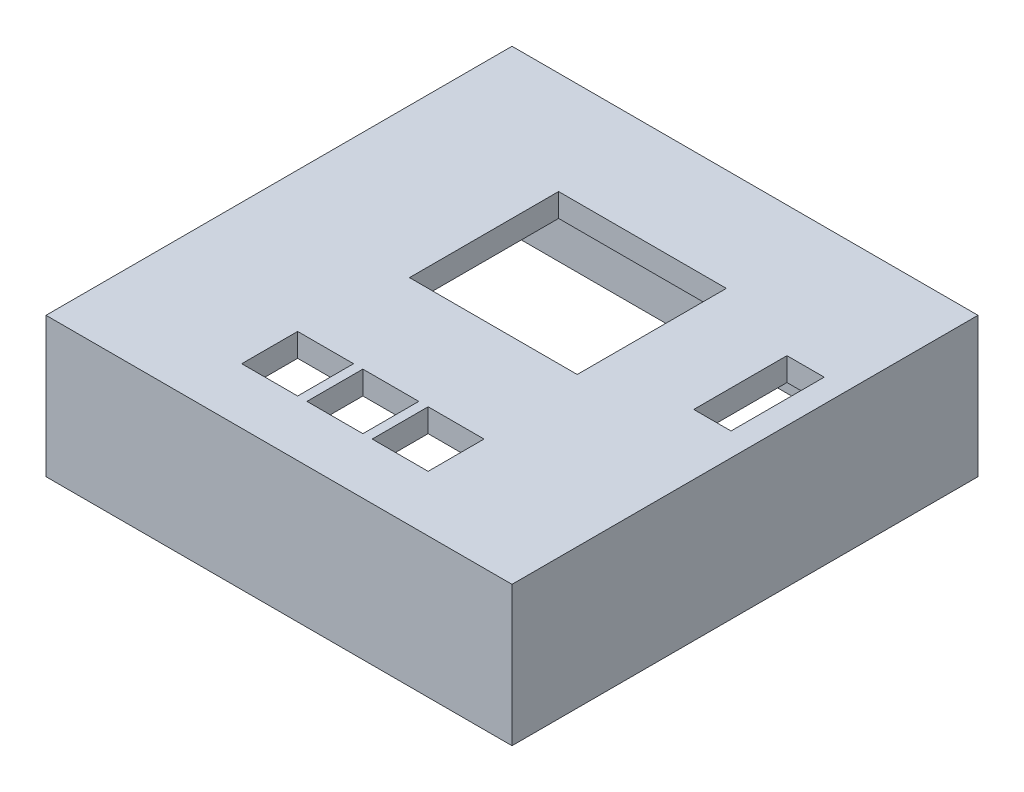
from build123d import *

# Parameters (mm, degrees)
SKETCH1_W                 = 100
SKETCH1_H                 = 100
BOSS_EXTRUDE1_DEPTH       = 30
SHELL2_T                  = -5
SKETCH2_W                 = 100
SKETCH2_H                 = 100
BOSS_EXTRUDE2_DEPTH       = 5
SKETCH3_W                 = 12
SKETCH3_H                 = 12
SKETCH3_W_2               = 36
SKETCH3_H_2               = 32
SKETCH3_W_3               = 8
SKETCH3_H_3               = 20
CUT_EXTRUDE1_DEPTH        = 5
SKETCH5_W                 = 10
SKETCH5_H                 = 10
CUT_EXTRUDE2_DEPTH        = 5
SKETCH6_W                 = 29
SKETCH6_H                 = 10
CUT_EXTRUDE3_DEPTH        = 5
SKETCH8_W                 = 100
SKETCH8_H                 = 100
CUT_EXTRUDE4_DEPTH        = 5
F_4_0MM_DOWEL_HOLE1_D     = 4
F_4_0MM_DOWEL_HOLE1_DEPTH = 5
F_4_0MM_DOWEL_HOLE1_TIP   = 1.201721238


with BuildPart() as part:
    # Sketch1 → Boss-Extrude1 (new body)
    with BuildSketch(Plane(origin=(0, 0, 0), x_dir=(1, 0, 0), z_dir=(0, 1, 0))):
        Rectangle(SKETCH1_W, SKETCH1_H)
    extrude(amount=BOSS_EXTRUDE1_DEPTH)

    # Shell2
    shell2_openings = [part.faces().sort_by_distance(p)[0] for p in [
        (0, 30, 0),
    ]]
    offset(amount=SHELL2_T, openings=shell2_openings, kind=Kind.INTERSECTION)

    # Sketch2 → Boss-Extrude2 (add)
    with BuildSketch(Plane(origin=(0, 30, 0), x_dir=(1, 0, 0), z_dir=(0, 1, 0))):
        Rectangle(SKETCH2_W, SKETCH2_H)
    extrude(amount=BOSS_EXTRUDE2_DEPTH)

    # Sketch3 → Cut-Extrude1 (cut)
    with BuildSketch(Plane(origin=(0, 35, 0), x_dir=(1, 0, 0), z_dir=(0, 1, 0))):
        with Locations((-14, -32)):
            Rectangle(SKETCH3_W, SKETCH3_H)
        with Locations((0, -32)):
            Rectangle(SKETCH3_W, SKETCH3_H)
        with Locations((14, -32)):
            Rectangle(SKETCH3_W, SKETCH3_H)
        with Locations((0, 12)):
            Rectangle(SKETCH3_W_2, SKETCH3_H_2)
        with Locations((41, 12)):
            Rectangle(SKETCH3_W_3, SKETCH3_H_3)
    extrude(amount=-CUT_EXTRUDE1_DEPTH, mode=Mode.SUBTRACT)

    # Sketch5 → Cut-Extrude2 (cut)
    with BuildSketch(Plane.ZY.offset(50)):
        with Locations((40, 25)):
            Rectangle(SKETCH5_W, SKETCH5_H)
    extrude(amount=-CUT_EXTRUDE2_DEPTH, mode=Mode.SUBTRACT)

    # Sketch6 → Cut-Extrude3 (cut)
    with BuildSketch(Plane(origin=(0, 0, -50), x_dir=(-1, 0, 0), z_dir=(0, 0, -1))):
        with Locations((25.5, 25)):
            Rectangle(SKETCH6_W, SKETCH6_H)
    extrude(amount=-CUT_EXTRUDE3_DEPTH, mode=Mode.SUBTRACT)

    # Sketch8 → Cut-Extrude4 (cut)
    with BuildSketch(Plane.XZ):
        Rectangle(SKETCH8_W, SKETCH8_H)
    extrude(amount=-CUT_EXTRUDE4_DEPTH, mode=Mode.SUBTRACT)

    # Ø4.0mm Dowel Hole1
    with Locations(Plane(origin=(-47.5, 5, 46), x_dir=(0, 0, -1), z_dir=(0, -1, 0))):
        with Locations((0, 0), (0, 95), (92, 95), (92, 0)):
            Hole(F_4_0MM_DOWEL_HOLE1_D / 2, depth=F_4_0MM_DOWEL_HOLE1_DEPTH)
            with Locations((0, 0, -(F_4_0MM_DOWEL_HOLE1_DEPTH + F_4_0MM_DOWEL_HOLE1_TIP / 2))):  # 118° drill point
                Cone(0, F_4_0MM_DOWEL_HOLE1_D / 2, F_4_0MM_DOWEL_HOLE1_TIP, mode=Mode.SUBTRACT)


solid = part.part
